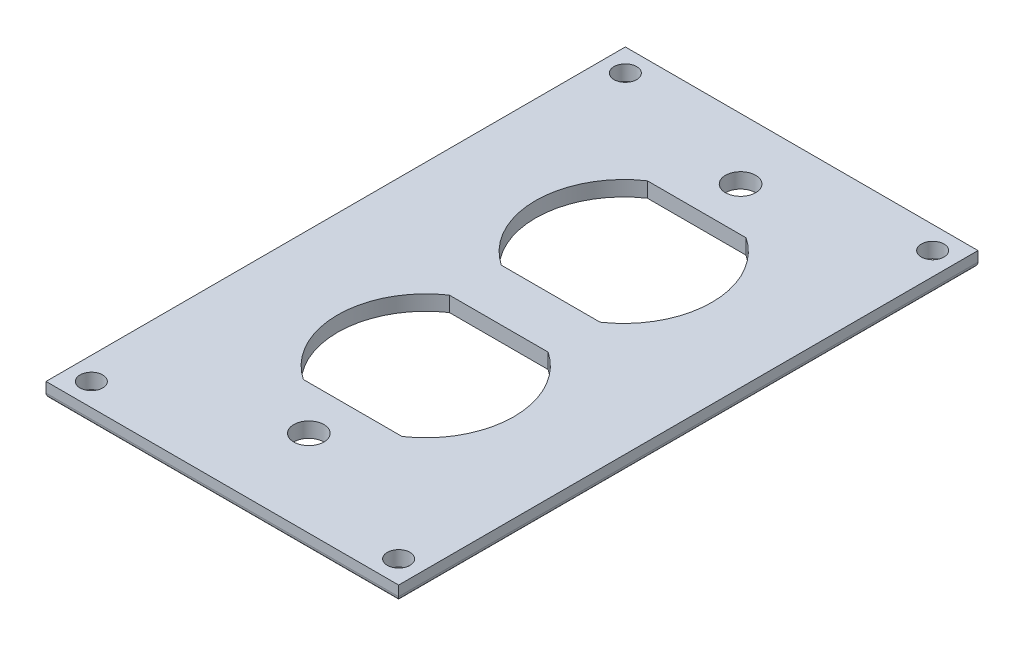
from build123d import *

# Parameters (mm, degrees)
SKETCH1_W                                  = 70
SKETCH1_H                                  = 115
BOSS_EXTRUDE1_DEPTH                        = 3
SKETCH4_R                                  = 2.25
CUT_EXTRUDE2_DEPTH                         = 3
MIRROR1_AT_THE_SECOND_PLANE_COPY_1_SKETC_R = 2.25
MIRROR1_AT_THE_SECOND_PLANE_COPY_1_DEPTH   = 3
FILLET4_R                                  = 1
CUT_EXTRUDE13_START                        = -3
CUT_EXTRUDE13_DEPTH                        = 4
SKETCH21_R                                 = 3
CUT_EXTRUDE14_DEPTH                        = 3


with BuildPart() as part:
    # Sketch1 → Boss-Extrude1 (new body)
    with BuildSketch(Plane(origin=(0, 0, 0), x_dir=(1, 0, 0), z_dir=(0, 1, 0))):
        Rectangle(SKETCH1_W, SKETCH1_H)
    extrude(amount=BOSS_EXTRUDE1_DEPTH)

    # Sketch4 → Cut-Extrude2 (cut)
    with BuildSketch(Plane(origin=(0, 0, 0), x_dir=(-1, 0, 0), z_dir=(0, -1, 0))):
        with Locations((30.5, -53)):
            Circle(SKETCH4_R)
    cut_extrude2 = extrude(amount=-CUT_EXTRUDE2_DEPTH, mode=Mode.SUBTRACT)

    # Mirror1: Cut-Extrude2 across plane
    add(cut_extrude2.mirror(Plane(origin=(0, 0, 0), x_dir=(0, 0, 1), z_dir=(1, 0, 0))), mode=Mode.SUBTRACT)

    # Mirror1 at the second plane: Cut-Extrude2 across plane
    add(cut_extrude2.mirror(Plane.XY), mode=Mode.SUBTRACT)

    # Mirror1 at the second plane copy 1 sketc → Mirror1 at the second plane copy 1 (cut)
    with BuildSketch(Plane.XZ):
        with Locations((30.5, -53)):
            Circle(MIRROR1_AT_THE_SECOND_PLANE_COPY_1_SKETC_R)
    extrude(amount=-MIRROR1_AT_THE_SECOND_PLANE_COPY_1_DEPTH, mode=Mode.SUBTRACT)

    # Fillet4
    fillet4_edges = [part.edges().sort_by_distance(p)[0] for p in [
        (0, 0, 57.5),
        (-35, 0, 0),
        (0, 0, -57.5),
        (35, 0, 0),
    ]]
    fillet(fillet4_edges, radius=FILLET4_R)

    # Sketch18 → Cut-Extrude13 (cut)
    with BuildSketch(Plane(origin=(0, 0, 0), x_dir=(-1, 0, 0), z_dir=(0, -1, 0)).offset(CUT_EXTRUDE13_START)):
        with BuildLine():
            Line((-9.797958971, -31.625), (9.797958971, -31.625))
            ThreePointArc((9.797958971, -31.625), (17.5, -17.125), (9.797958971, -2.625))
            Line((9.797958971, -2.625), (-9.797958971, -2.625))
            ThreePointArc((-9.797958971, -2.625), (-17.5, -17.125), (-9.797958971, -31.625))
        make_face()
    cut_extrude13 = extrude(amount=CUT_EXTRUDE13_DEPTH, mode=Mode.SUBTRACT)

    # Mirror3: Cut-Extrude13 across plane
    add(cut_extrude13.mirror(Plane.XY.offset(-2.525)), mode=Mode.SUBTRACT)

    # Sketch21 → Cut-Extrude14 (cut)
    with BuildSketch(Plane(origin=(0, 3, 0), x_dir=(1, 0, 0), z_dir=(0, 1, 0))):
        with Locations((0, 45.375)):
            Circle(SKETCH21_R)
        with Locations((0, -40.325)):
            Circle(SKETCH21_R)
    extrude(amount=-CUT_EXTRUDE14_DEPTH, mode=Mode.SUBTRACT)


solid = part.part
